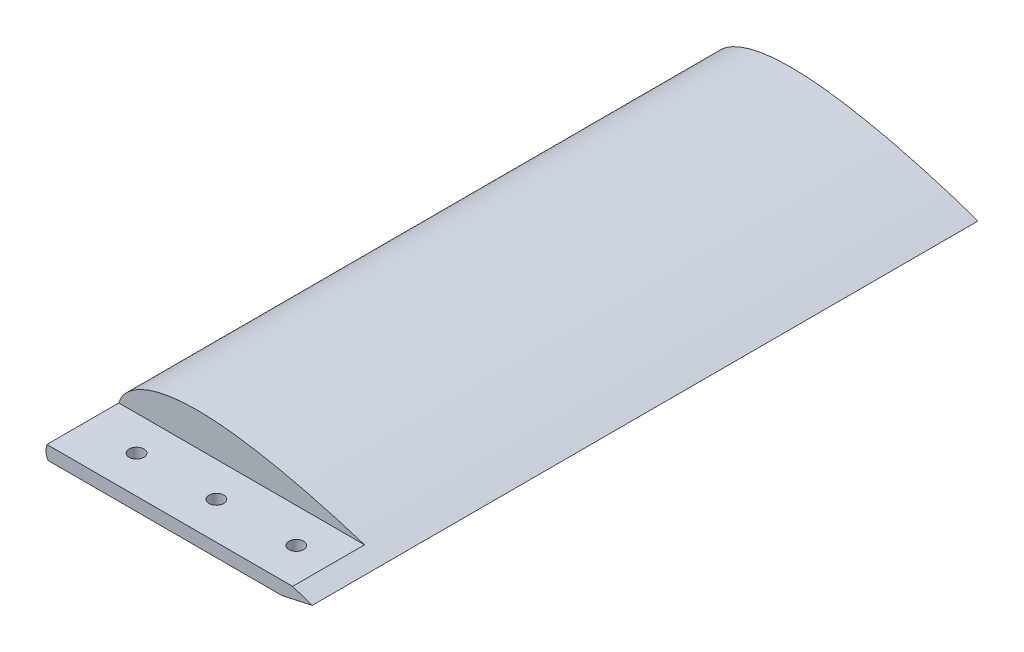
from build123d import *

# Parameters (mm, degrees)
BOSS_EXTRUDE1_DEPTH     = 125
CUT_EXTRUDE1_DEPTH      = 90
CUT_EXTRUDE1_DEPTH_BACK = 110
SKETCH9_OUTSIDE_W       = 156.08
SKETCH9_OUTSIDE_H       = 80.93
SKETCH9_OUTSIDE_W_2     = 100
SKETCH9_OUTSIDE_H_2     = 5
CUT_EXTRUDE2_DEPTH      = 27
M5_CLEARANCE_HOLE1_D    = 5.5
SKETCH15_W              = 15
SKETCH15_H              = 10
CUT_EXTRUDE3_DEPTH      = 10


with BuildPart() as part:
    # Sketch1 → Boss-Extrude1 (new body, symmetric)
    with BuildSketch(Plane.XY):
        with BuildLine():
            add(Edge.make_bspline(
                [(0, 0), (0.000850995, 0.329659199), (0.029549865, 0.927472015), (0.14385133, 1.796745902), (0.437026819, 2.918116545), (0.854897816, 3.99067399), (1.431457873, 5.075606208), (2.192315162, 6.177305776), (3.200330795, 7.329994922), (4.495933807, 8.510625759), (6.154032841, 9.714948919), (8.274086435, 10.929186229), (10.956963281, 12.114631433), (14.147653492, 13.152534318), (18.040460609, 14.036328853), (23.13432232, 14.736569605), (29.235682959, 15.027445823), (35.337980191, 14.824799668), (41.101061226, 14.313753112), (46.84100573, 13.596774566), (51.603718071, 12.850513756), (56.345578755, 11.983351698), (61.067148387, 11.013921336), (64.832774323, 10.182970339), (68.586460194, 9.301464098), (72.329426272, 8.372556112), (76.059801155, 7.399362237), (79.315748534, 6.509324276), (82.095955547, 5.720960272), (84.412746103, 5.044415193), (86.253737616, 4.495737821), (88.110746108, 3.929395104), (89.928948501, 3.364622885), (91.806033909, 2.766575591), (93.571042413, 2.195551738), (95.520153622, 1.546294126), (97.13830136, 1.000944859), (98.775140125, 0.431667147), (99.586664269, 0.14652965), (100.000220498, 0)],
                knots=[0, 0, 0, 0, 0, 0.011046069, 0.020081733, 0.029325805, 0.03880189, 0.049580055, 0.06120956, 0.074146174, 0.090070544, 0.108265326, 0.129826997, 0.155964864, 0.18830697, 0.220649281, 0.263591413, 0.32827592, 0.392960436, 0.425302696, 0.457644956, 0.52232947, 0.55467173, 0.58701399, 0.619356253, 0.651698515, 0.684040775, 0.716383035, 0.748725291, 0.764896419, 0.781067547, 0.797238677, 0.813409806, 0.829580935, 0.845752065, 0.861923198, 0.878094331, 0.894265464, 0.910433902, 0.910433902, 0.910433902, 0.910433902, 0.910433902], degree=4))
            add(Edge.make_bspline(
                [(0, 0), (0.000283694, -0.169267254), (0.015976794, -0.461371136), (0.077487025, -0.88514164), (0.233270026, -1.435649885), (0.451244669, -1.960918505), (0.763020391, -2.515682909), (1.196819683, -3.111846412), (1.800946429, -3.766711239), (2.645862845, -4.495413172), (3.845009807, -5.315163118), (5.520192869, -6.210587445), (7.890487327, -7.180714875), (10.947062049, -8.096276481), (15.429604607, -9.039640979), (21.207967366, -9.730011133), (27.977535992, -10.02746215), (35.648602876, -9.889128299), (42.346864335, -9.465706657), (48.074827103, -8.93985543), (53.791477179, -8.306095929), (59.496830619, -7.576550222), (65.188499989, -6.746051578), (70.86666832, -5.830240622), (75.589869863, -5.014181774), (79.362447213, -4.33071773), (82.659602016, -3.705830248), (85.480106996, -3.151491524), (87.596226543, -2.723280533), (89.000489113, -2.434123885), (90.181059485, -2.187185496), (91.104029231, -1.992562417), (92.305099816, -1.735390328), (93.655404022, -1.443860687), (95.389810689, -1.059643077), (97.102663756, -0.674849293), (98.714450572, -0.301843412), (99.575627153, -0.100232022), (100.000220498, 0)],
                knots=[0, 0, 0, 0, 0, 0.005887152, 0.010193359, 0.014866851, 0.019889426, 0.025655397, 0.032314697, 0.040497527, 0.050864902, 0.064448179, 0.082823086, 0.106555664, 0.139953895, 0.175459216, 0.242255956, 0.309052716, 0.375849477, 0.442646237, 0.47604462, 0.509443003, 0.576239764, 0.643036527, 0.676434909, 0.709833291, 0.743231671, 0.77663005, 0.793329242, 0.810028433, 0.818378029, 0.826727624, 0.83507722, 0.843426816, 0.860126007, 0.876825198, 0.893524389, 0.91022358, 0.91022358, 0.91022358, 0.91022358, 0.91022358], degree=4))
        make_face()
    extrude(amount=BOSS_EXTRUDE1_DEPTH, both=True)

    # Sketch6 → Cut-Extrude1 (cut, two sides)
    with BuildSketch(Plane.XY) as cut_extrude1_sk:
        with BuildLine():
            add(Edge.make_bspline(
                [(5.003866411, 0.16593331), (5.021771107, 0.603167174), (5.179582681, 1.45668418), (5.828059264, 2.731623867), (6.970434665, 4.055197794), (9.059941641, 5.70999826), (12.439790451, 7.406031049), (17.102385774, 8.772586441), (22.086939339, 9.580996278), (28.969887571, 10.04915127), (37.811358565, 9.719164197), (48.519550578, 8.365627259), (62.800967104, 5.688073766), (73.468720144, 2.987314718), (80.492223408, 0.975075783)],
                knots=[0.003107056, 0.003107056, 0.003107056, 0.003107056, 0.026472192, 0.049837329, 0.073202466, 0.096567602, 0.143297876, 0.190028149, 0.236758422, 0.283488695, 0.376949242, 0.470409788, 0.563870335, 0.750791428, 0.750791428, 0.750791428, 0.750791428], degree=3))
            add(Edge.make_bspline(
                [(80.492223408, 0.975075783), (73.808709309, -0.294311553), (63.724097701, -1.995472923), (50.2739718, -3.721966825), (40.201550005, -4.64981718), (31.854573956, -4.99623266), (25.257558055, -4.894657534), (20.376304938, -4.583057975), (16.407020376, -4.077297068), (13.341823588, -3.482519629), (11.126614852, -2.928004065), (9.036775347, -2.250698534), (7.465669402, -1.576012545), (6.39422808, -0.985208256), (5.718999313, -0.532122097), (5.309123649, -0.182799424), (5.089567118, 0.053028449), (5.034725373, 0.122545069), (5.003866411, 0.16593331)],
                knots=[0.025550827, 0.025550827, 0.025550827, 0.025550827, 0.20536823, 0.295276931, 0.385185632, 0.475094334, 0.520048685, 0.565003035, 0.609957386, 0.632434561, 0.654911737, 0.677388912, 0.699866088, 0.711104675, 0.722343263, 0.733581851, 0.739201144, 0.744820438, 0.744820438, 0.744820438, 0.744820438], degree=3))
        make_face()
    extrude(amount=CUT_EXTRUDE1_DEPTH, mode=Mode.SUBTRACT)
    extrude(cut_extrude1_sk.sketch, amount=-CUT_EXTRUDE1_DEPTH_BACK, mode=Mode.SUBTRACT)

    # Sketch9 outside → Cut-Extrude2 (cut)
    with BuildSketch(Plane.XY.offset(125)):
        with Locations((50, 2.485)):
            Rectangle(SKETCH9_OUTSIDE_W, SKETCH9_OUTSIDE_H)
        with Locations((50, 0)):
            Rectangle(SKETCH9_OUTSIDE_W_2, SKETCH9_OUTSIDE_H_2, mode=Mode.SUBTRACT)
    extrude(amount=-CUT_EXTRUDE2_DEPTH, mode=Mode.SUBTRACT)

    # M5 Clearance Hole1 (through all)
    with Locations(Plane(origin=(0, 2.5, 0), x_dir=(1, 0, 0), z_dir=(0, 1, 0))):
        with Locations((20.000045484, -111), (80.000045484, -111), (-19.77166383, -210), (50.000045484, -111)):
            Hole(M5_CLEARANCE_HOLE1_D / 2)

    # Sketch15 → Cut-Extrude3 (cut)
    with BuildSketch(Plane(origin=(0, 0, -125), x_dir=(-1, 0, 0), z_dir=(0, 0, -1))):
        with Locations((-35, 0)):
            Rectangle(SKETCH15_W, SKETCH15_H)
        with Locations((-55, 0)):
            Rectangle(SKETCH15_W, SKETCH15_H)
        with Locations((-15, 0)):
            Rectangle(SKETCH15_W, SKETCH15_H)
    extrude(amount=-CUT_EXTRUDE3_DEPTH, mode=Mode.SUBTRACT)


solid = part.part
